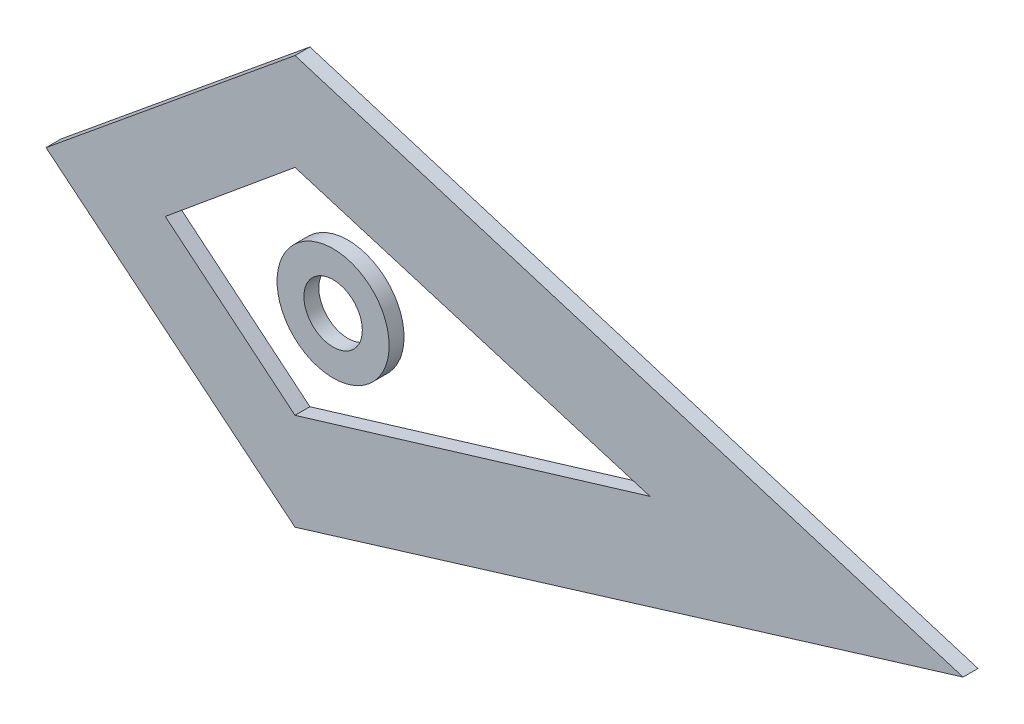
from build123d import *

# Parameters (mm, degrees)
BOSS_EXTRUDE1_DEPTH   = 2.54
SKETCH1_R             = 9.546523702
SKETCH1_R_2           = 4.974523702
BOSS_EXTRUDE1_2_DEPTH = 2.54


with BuildPart() as part:
    # Sketch1 → Boss-Extrude1 (new body)
    with BuildSketch(Plane.XY):
        Polygon((-48.916523702, 0), (-6.491780802, 34.798), (107.336523702, 0), (-6.491780802, -34.798), align=None)
        Polygon((-28.596523702, 0), (-6.491780802, -18.288), (53.996523702, 0), (-6.491780802, 18.288), align=None, mode=Mode.SUBTRACT)
    extrude(amount=BOSS_EXTRUDE1_DEPTH)


with BuildPart() as body_2:
    # Sketch1 → Boss-Extrude1 2 (new body)
    with BuildSketch(Plane.XY):
        Circle(SKETCH1_R)
        Circle(SKETCH1_R_2, mode=Mode.SUBTRACT)
    extrude(amount=BOSS_EXTRUDE1_2_DEPTH)


solid = Compound([part.part, body_2.part])
